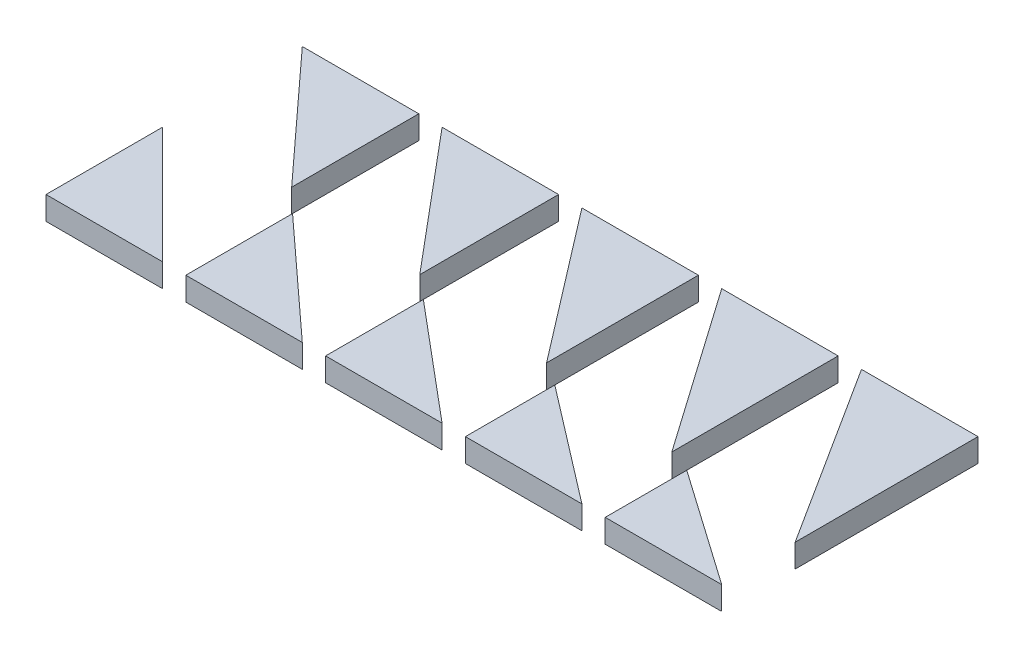
from build123d import *

# Parameters (mm, degrees)
BOSS_EXTRUDE1_DEPTH    = 10
BOSS_EXTRUDE1_2_DEPTH  = 10
BOSS_EXTRUDE1_3_DEPTH  = 10
BOSS_EXTRUDE1_4_DEPTH  = 10
BOSS_EXTRUDE1_5_DEPTH  = 10
BOSS_EXTRUDE1_6_DEPTH  = 10
BOSS_EXTRUDE1_7_DEPTH  = 10
BOSS_EXTRUDE1_8_DEPTH  = 10
BOSS_EXTRUDE1_9_DEPTH  = 10
BOSS_EXTRUDE1_10_DEPTH = 10


with BuildPart() as part:
    # Sketch1 → Boss-Extrude1 (new body)
    with BuildSketch(Plane(origin=(0, 0, 0), x_dir=(1, 0, 0), z_dir=(0, 1, 0))):
        Polygon((50, 55.434574947), (50, 110), (0, 110), align=None)
    extrude(amount=BOSS_EXTRUDE1_DEPTH)


with BuildPart() as body_2:
    # Sketch1 → Boss-Extrude1 2 (new body)
    with BuildSketch(Plane(origin=(0, 0, 0), x_dir=(1, 0, 0), z_dir=(0, 1, 0))):
        Polygon((110, 50.41232037), (110, 110), (60, 110), align=None)
    extrude(amount=BOSS_EXTRUDE1_2_DEPTH)


with BuildPart() as body_3:
    # Sketch1 → Boss-Extrude1 3 (new body)
    with BuildSketch(Plane(origin=(0, 0, 0), x_dir=(1, 0, 0), z_dir=(0, 1, 0))):
        Polygon((170, 110), (120, 110), (170, 44.838731358), align=None)
    extrude(amount=BOSS_EXTRUDE1_3_DEPTH)


with BuildPart() as body_4:
    # Sketch1 → Boss-Extrude1 4 (new body)
    with BuildSketch(Plane(origin=(0, 0, 0), x_dir=(1, 0, 0), z_dir=(0, 1, 0))):
        Polygon((230, 38.592599663), (230, 110), (180, 110), align=None)
    extrude(amount=BOSS_EXTRUDE1_4_DEPTH)


with BuildPart() as body_5:
    # Sketch1 → Boss-Extrude1 5 (new body)
    with BuildSketch(Plane(origin=(0, 0, 0), x_dir=(1, 0, 0), z_dir=(0, 1, 0))):
        Polygon((290, 31.515721144), (290, 110), (240, 110), align=None)
    extrude(amount=BOSS_EXTRUDE1_5_DEPTH)


with BuildPart() as body_6:
    # Sketch1 → Boss-Extrude1 6 (new body)
    with BuildSketch(Plane(origin=(0, 0, 0), x_dir=(1, 0, 0), z_dir=(0, 1, 0))):
        Polygon((290, 0), (240, 35.01037691), (240, 0), align=None)
    extrude(amount=BOSS_EXTRUDE1_6_DEPTH)


with BuildPart() as body_7:
    # Sketch1 → Boss-Extrude1 7 (new body)
    with BuildSketch(Plane(origin=(0, 0, 0), x_dir=(1, 0, 0), z_dir=(0, 1, 0))):
        Polygon((230, 0), (180, 38.366349399), (180, 0), align=None)
    extrude(amount=BOSS_EXTRUDE1_7_DEPTH)


with BuildPart() as body_8:
    # Sketch1 → Boss-Extrude1 8 (new body)
    with BuildSketch(Plane(origin=(0, 0, 0), x_dir=(1, 0, 0), z_dir=(0, 1, 0))):
        Polygon((170, 0), (120, 41.954981559), (120, 0), align=None)
    extrude(amount=BOSS_EXTRUDE1_8_DEPTH)


with BuildPart() as body_9:
    # Sketch1 → Boss-Extrude1 9 (new body)
    with BuildSketch(Plane(origin=(0, 0, 0), x_dir=(1, 0, 0), z_dir=(0, 1, 0))):
        Polygon((110, 0), (60, 45.816558701), (60, 0), align=None)
    extrude(amount=BOSS_EXTRUDE1_9_DEPTH)


with BuildPart() as body_10:
    # Sketch1 → Boss-Extrude1 10 (new body)
    with BuildSketch(Plane(origin=(0, 0, 0), x_dir=(1, 0, 0), z_dir=(0, 1, 0))):
        Polygon((50, 0), (0, 50), (0, 0), align=None)
    extrude(amount=BOSS_EXTRUDE1_10_DEPTH)


solid = Compound([part.part, body_2.part, body_3.part, body_4.part, body_5.part, body_6.part, body_7.part, body_8.part, body_9.part, body_10.part])
